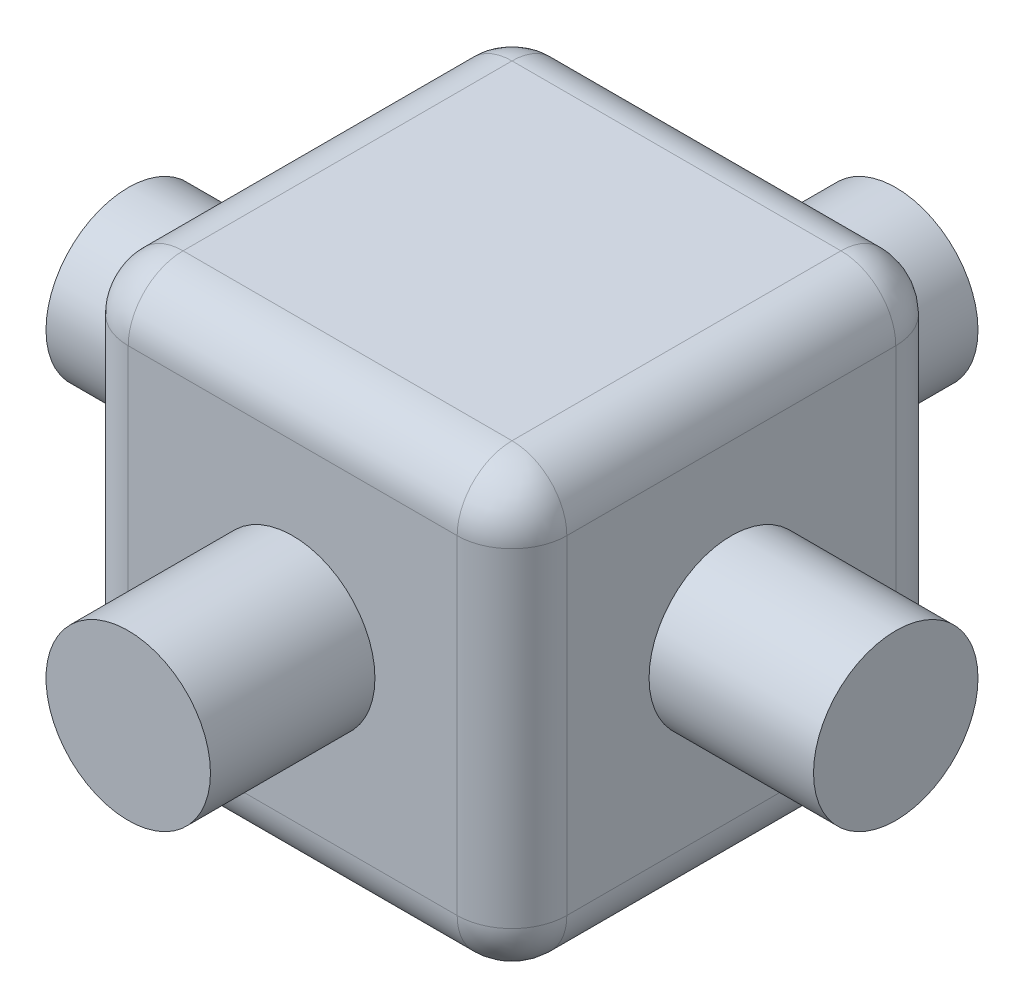
from build123d import *

# Parameters (mm, degrees)
SKETCH1_R           = 0.75
BOSS_EXTRUDE1_DEPTH = 3.5
CIRPATTERN1_COUNT   = 4
SKETCH3_W           = 4
SKETCH3_H           = 4
SKETCH3_W_2         = 1.5
SKETCH3_H_2         = 1.5
BOSS_EXTRUDE2_DEPTH = 2
FILLET1_R           = 0.5


with BuildPart() as part:
    # Sketch1 → Boss-Extrude1 (new, symmetric)
    with BuildSketch(Plane.XY):
        Circle(SKETCH1_R)
    boss_extrude1 = extrude(amount=BOSS_EXTRUDE1_DEPTH, both=True)

    # CirPattern1: Boss-Extrude1 ×4 about axis
    cirpattern1_axis = Axis((0, -1.485, 0), (0, 1, 0))
    for i in range(1, CIRPATTERN1_COUNT):
        add(boss_extrude1.rotate(cirpattern1_axis, i * 360 / CIRPATTERN1_COUNT))

    # Sketch3 → Boss-Extrude2 (add, symmetric)
    with BuildSketch(Plane(origin=(0, 0, 0), x_dir=(1, 0, 0), z_dir=(0, 1, 0))):
        Rectangle(SKETCH3_W, SKETCH3_H)
        Rectangle(SKETCH3_W_2, SKETCH3_H_2, mode=Mode.SUBTRACT)
        Rectangle(SKETCH3_W_2, SKETCH3_H_2)
    extrude(amount=BOSS_EXTRUDE2_DEPTH, both=True)

    # Fillet1
    fillet1_edges = [part.edges().sort_by_distance(p)[0] for p in [
        (0, 2, 2),
        (-2, 0, 2),
        (2, -2, 0),
        (2, 0, 2),
        (0, -2, -2),
        (2, 0, -2),
        (-2, 2, 0),
        (-2, 0, -2),
        (2, 2, 0),
        (0, 2, -2),
        (0, -2, 2),
        (-2, -2, 0),
    ]]
    fillet(fillet1_edges, radius=FILLET1_R)


solid = part.part
